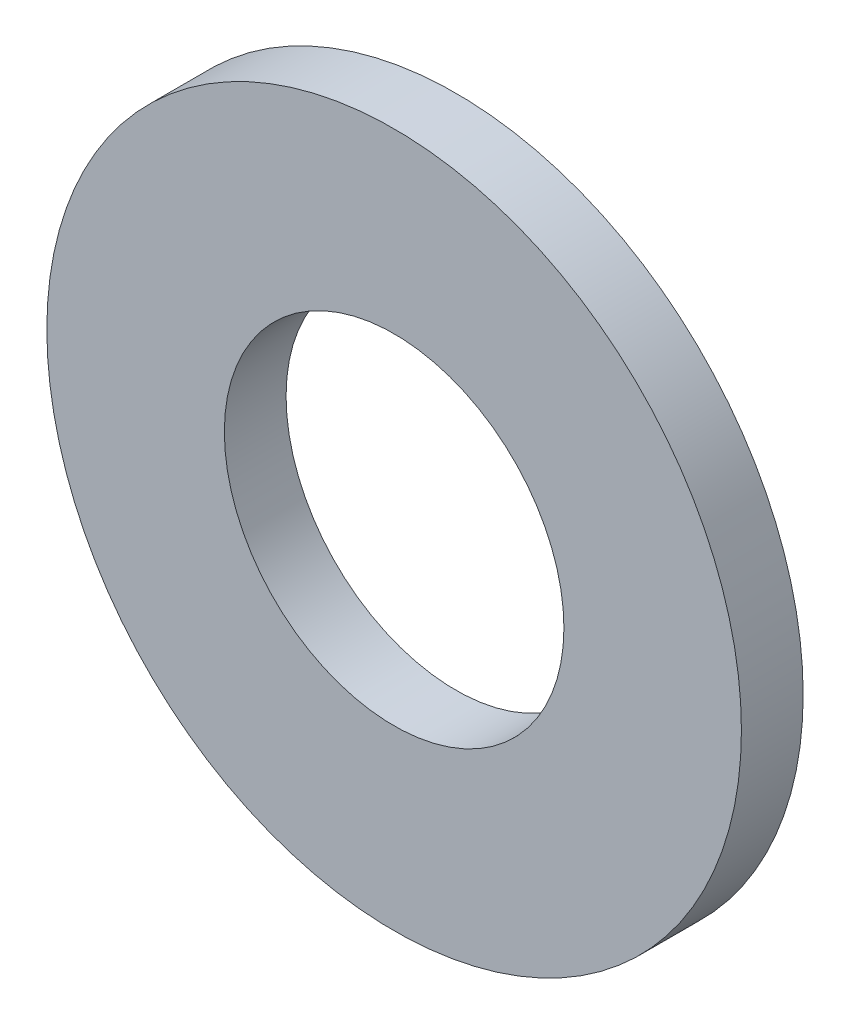
from build123d import *

# Parameters (mm, degrees)
SKETCH1_R           = 2.25
SKETCH1_R_2         = 1.1
BOSS_EXTRUDE1_DEPTH = 0.4


with BuildPart() as part:
    # Sketch1 → Boss-Extrude1 (new body)
    with BuildSketch(Plane.XY):
        Circle(SKETCH1_R)
        Circle(SKETCH1_R_2, mode=Mode.SUBTRACT)
    extrude(amount=BOSS_EXTRUDE1_DEPTH)


solid = part.part
